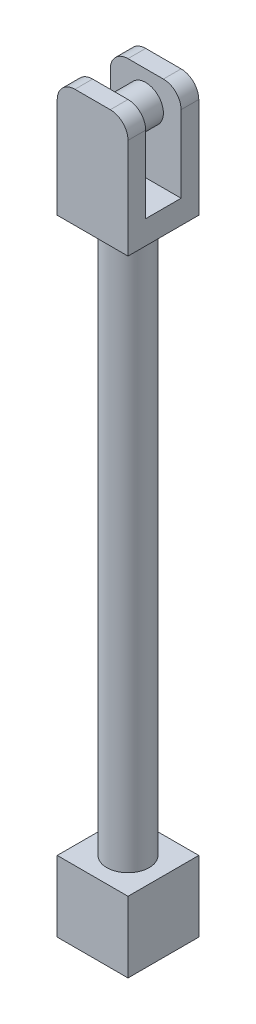
from build123d import *

# Parameters (mm, degrees)
SKETCH1_W           = 30
SKETCH1_H           = 30
BOSS_EXTRUDE1_DEPTH = 30
SKETCH2_R           = 9
BOSS_EXTRUDE2_DEPTH = 235
SKETCH3_W           = 30
SKETCH3_H           = 30
BOSS_EXTRUDE3_DEPTH = 50
SKETCH4_W           = 30
SKETCH4_H           = 15
CUT_EXTRUDE1_DEPTH  = 40
SKETCH5_R           = 7.5
BOSS_EXTRUDE4_DEPTH = 15
FILLET1_R           = 7.5


with BuildPart() as part:
    # Sketch1 → Boss-Extrude1 (new body)
    with BuildSketch(Plane(origin=(0, 0, 0), x_dir=(1, 0, 0), z_dir=(0, 1, 0))):
        Rectangle(SKETCH1_W, SKETCH1_H)
    extrude(amount=BOSS_EXTRUDE1_DEPTH)

    # Sketch2 → Boss-Extrude2 (add)
    with BuildSketch(Plane(origin=(0, 30, 0), x_dir=(1, 0, 0), z_dir=(0, 1, 0))):
        Circle(SKETCH2_R)
    extrude(amount=BOSS_EXTRUDE2_DEPTH)

    # Sketch3 → Boss-Extrude3 (add)
    with BuildSketch(Plane(origin=(0, 265, 0), x_dir=(1, 0, 0), z_dir=(0, 1, 0))):
        Rectangle(SKETCH3_W, SKETCH3_H)
    extrude(amount=BOSS_EXTRUDE3_DEPTH)

    # Sketch4 → Cut-Extrude1 (cut)
    with BuildSketch(Plane(origin=(0, 315, 0), x_dir=(1, 0, 0), z_dir=(0, 1, 0))):
        Rectangle(SKETCH4_W, SKETCH4_H)
    extrude(amount=-CUT_EXTRUDE1_DEPTH, mode=Mode.SUBTRACT)

    # Sketch5 → Boss-Extrude4 (add)
    with BuildSketch(Plane(origin=(0, 0, 7.5), x_dir=(-1, 0, 0), z_dir=(0, 0, -1))):
        with Locations((0, 302.5)):
            Circle(SKETCH5_R)
    extrude(amount=BOSS_EXTRUDE4_DEPTH)

    # Fillet1
    fillet1_edges = [part.edges().sort_by_distance(p)[0] for p in [
        (15, 315, 11.25),
        (-15, 315, -11.25),
        (15, 315, -11.25),
        (-15, 315, 11.25),
    ]]
    fillet(fillet1_edges, radius=FILLET1_R)


solid = part.part
